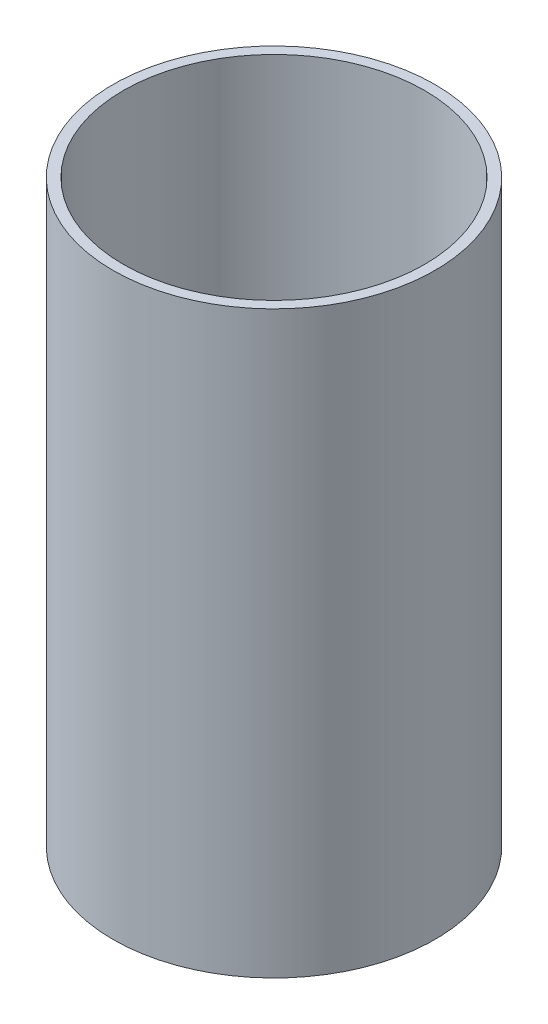
from build123d import *


with BuildPart() as part:
    # Sketch1 → Revolve1 (revolve)
    with BuildSketch(Plane.XY):
        Polygon((0, 0), (49.403, 0), (49.403, 177.8), (46.228, 177.8), (46.228, 3.175), (0, 3.175), align=None)
    revolve(axis=Axis((0, -8.89, 0), (0, 1, 0)))


solid = part.part
